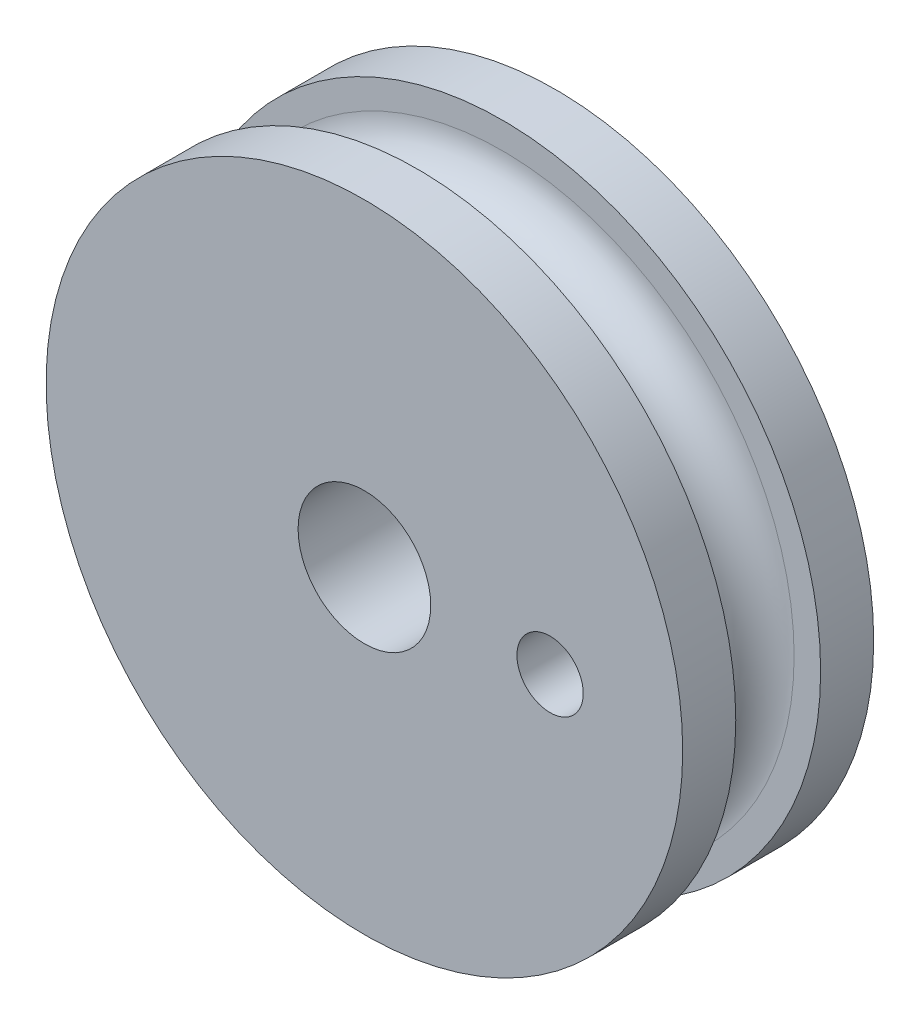
from build123d import *

# Parameters (mm, degrees)
SKETCH_1_R          = 12
EXTRUDE_1_DEPTH     = 2
SKETCH_2_R          = 11
EXTRUDE_2_DEPTH     = 3.2
SKETCH_3_R          = 12
EXTRUDE_3_DEPTH     = 2
SKETCH_4_R          = 2.5
CUT_EXTRUDE_1_DEPTH = 30
SKETCH_3D_1_R       = 1.597010155
M3X0_5_1_D          = 2.5
M3X0_5_1_DEPTH      = 8.5
M3X0_5_1_TIP        = 0.751075774


with BuildPart() as part:
    # ｽｹｯﾁ1 → ﾎﾞｽ - 押し出し1 (new body)
    with BuildSketch(Plane.XY):
        Circle(SKETCH_1_R)
    extrude(amount=EXTRUDE_1_DEPTH)

    # ｽｹｯﾁ2 → ﾎﾞｽ - 押し出し2 (add)
    with BuildSketch(Plane.XY.offset(2)):
        Circle(SKETCH_2_R)
    extrude(amount=EXTRUDE_2_DEPTH)

    # ｽｹｯﾁ3 → ﾎﾞｽ - 押し出し3 (add)
    with BuildSketch(Plane.XY.offset(5.2)):
        Circle(SKETCH_3_R)
    extrude(amount=EXTRUDE_3_DEPTH)

    # ｽｹｯﾁ4 → ｶｯﾄ - 押し出し1 (cut)
    with BuildSketch(Plane(origin=(0, 0, 0), x_dir=(-1, 0, 0), z_dir=(0, 0, -1))):
        Circle(SKETCH_4_R)
    extrude(amount=-CUT_EXTRUDE_1_DEPTH, mode=Mode.SUBTRACT)

    # ｶｯﾄ - ｽｲｰﾌﾟ1: sweep along a curve in space
    with BuildLine() as sweep_1_path:
        ThreePointArc((11, 0, 5.2), (7.778174593, 7.778174593, 5.2), (0, 11, 5.2))
        ThreePointArc((0, 11, 5.2), (-7.778174593, 7.778174593, 5.2), (-11, 0, 5.2))
        ThreePointArc((-11, 0, 5.2), (-7.778174593, -7.778174593, 5.2), (0, -11, 5.2))
        ThreePointArc((0, -11, 5.2), (7.778174593, -7.778174593, 5.2), (11, 0, 5.2))
    # Sketch 3D_1 → ｶｯﾄ - ｽｲｰﾌﾟ1 (sweep, cut)
    with BuildSketch(Plane(origin=(11, 0, 5.2), x_dir=(0, 0, -1), z_dir=(0, -1, 0))):
        with Locations((1.602989845, 0)):
            Circle(SKETCH_3D_1_R)
    sweep(path=sweep_1_path.line, mode=Mode.SUBTRACT)

    # M3x0.5 ねじ穴1
    with Locations(Plane(origin=(7, 0, 0), x_dir=(-1, 0, 0), z_dir=(0, 0, -1))):
        with Locations((0, 0)):
            Hole(M3X0_5_1_D / 2, depth=M3X0_5_1_DEPTH)
            with Locations((0, 0, -(M3X0_5_1_DEPTH + M3X0_5_1_TIP / 2))):  # 118° drill point
                Cone(0, M3X0_5_1_D / 2, M3X0_5_1_TIP, mode=Mode.SUBTRACT)


solid = part.part
